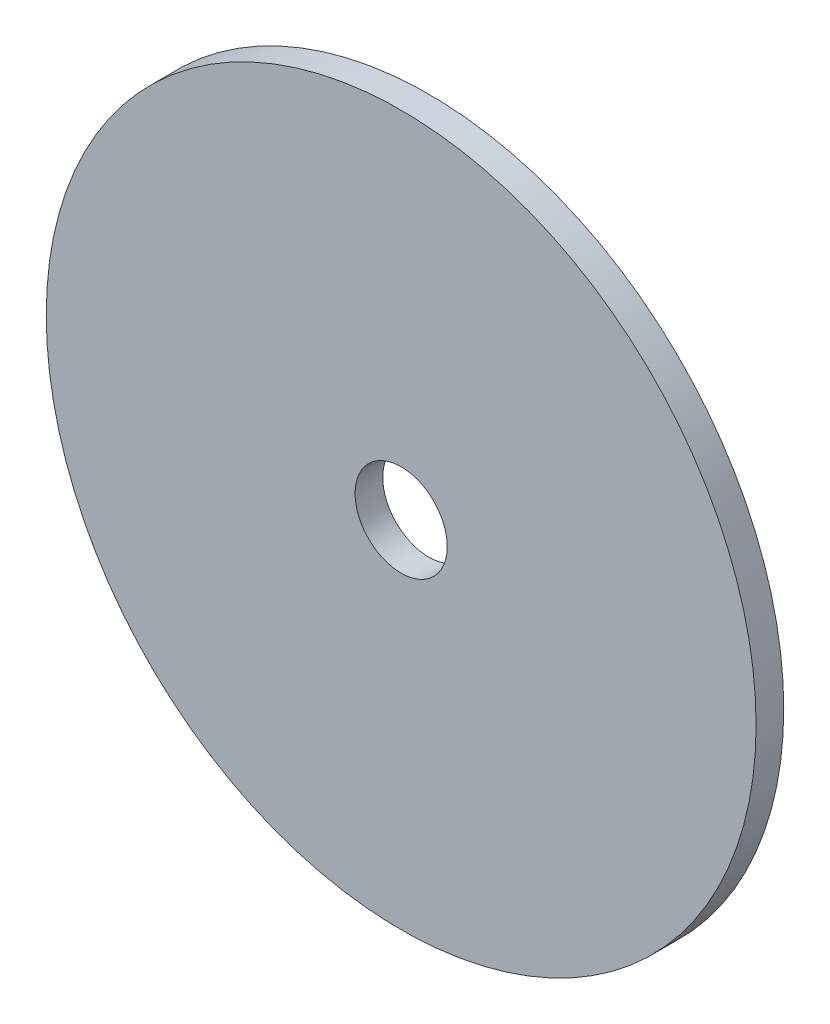
from build123d import *

# Parameters (mm, degrees)
CROQUIS1_R              = 77
SALIENTE_EXTRUIR1_DEPTH = 6
CROQUIS2_R              = 10
CORTAR_EXTRUIR1_DEPTH   = 36


with BuildPart() as part:
    # Croquis1 → Saliente-Extruir1 (new body)
    with BuildSketch(Plane.XY):
        Circle(CROQUIS1_R)
    extrude(amount=SALIENTE_EXTRUIR1_DEPTH)

    # Croquis2 → Cortar-Extruir1 (cut)
    with BuildSketch(Plane.XY.offset(6)):
        Circle(CROQUIS2_R)
    extrude(amount=-CORTAR_EXTRUIR1_DEPTH, mode=Mode.SUBTRACT)


solid = part.part
